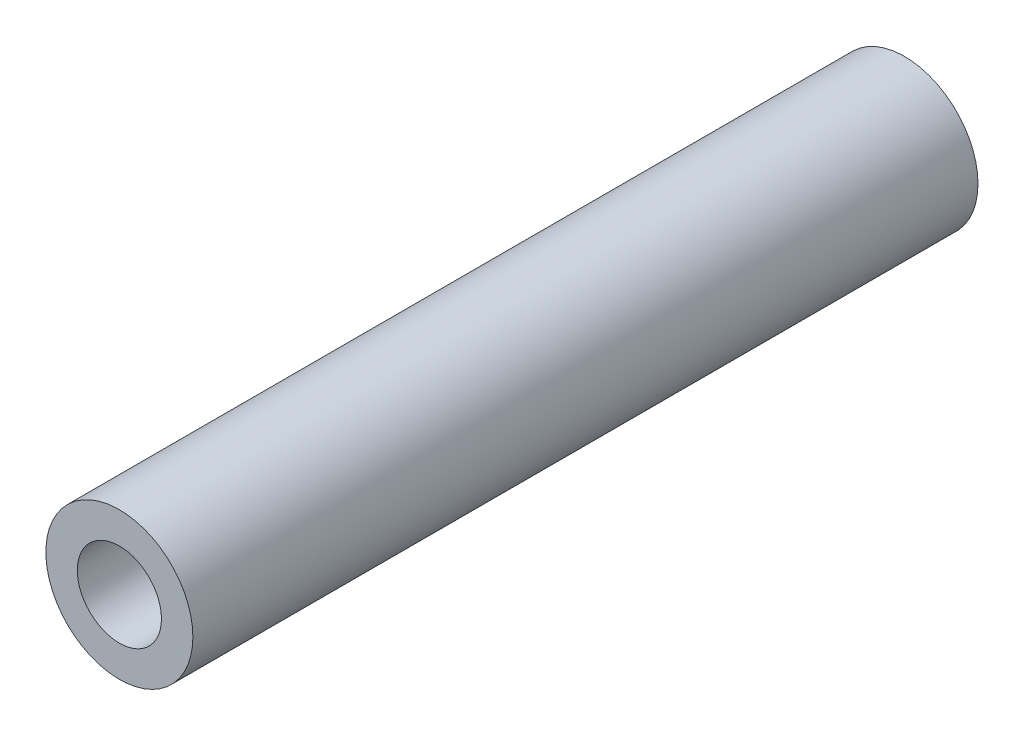
from build123d import *

# Parameters (mm, degrees)
SKETCH1_R           = 4.63
SKETCH1_R_2         = 2.65
BOSS_EXTRUDE1_DEPTH = 49.45


with BuildPart() as part:
    # Sketch1 → Boss-Extrude1 (new body)
    with BuildSketch(Plane.XY):
        with Locations((1803.99117355, -1743.849409116)):
            Circle(SKETCH1_R)
        with Locations((1803.99117355, -1743.849409116)):
            Circle(SKETCH1_R_2, mode=Mode.SUBTRACT)
    extrude(amount=BOSS_EXTRUDE1_DEPTH)


solid = part.part
